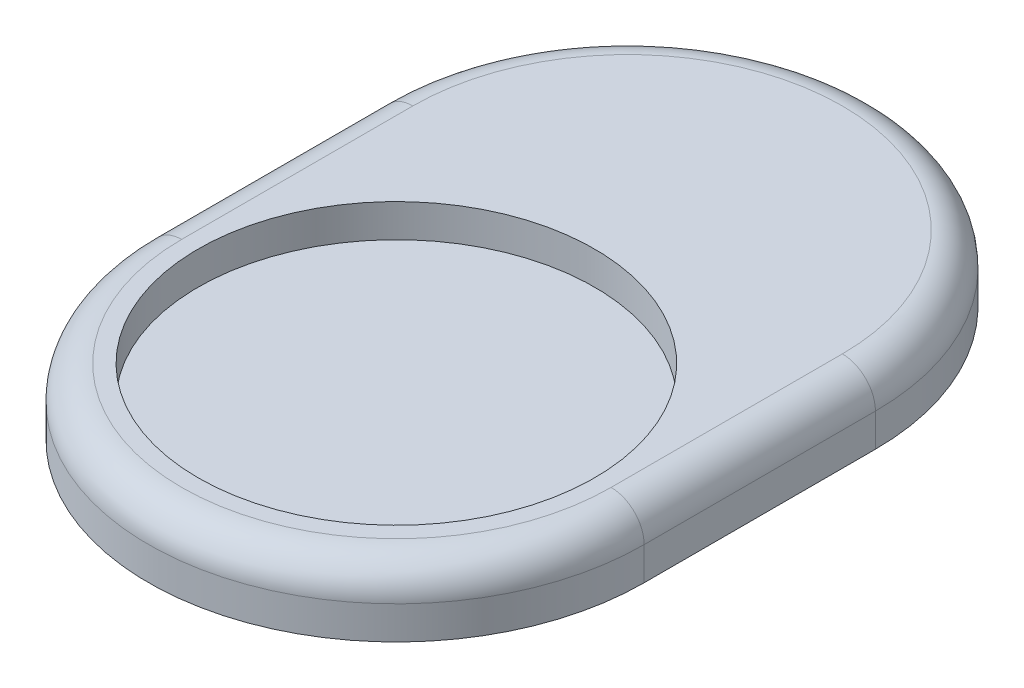
from build123d import *

# Parameters (mm, degrees)
BOSS_EXTRUDE2_DEPTH = 2
SKETCH3_R           = 6
CUT_EXTRUDE1_DEPTH  = 1
FILLET2_R           = 1


with BuildPart() as part:
    # Sketch2 → Boss-Extrude2 (new body)
    with BuildSketch(Plane(origin=(0, 0, 0), x_dir=(1, 0, 0), z_dir=(0, 1, 0))):
        with BuildLine():
            Line((-7.5, 0), (-7.5, 7))
            ThreePointArc((-7.5, 7), (0, 14.5), (7.5, 7))
            Line((7.5, 7), (7.5, 0))
            ThreePointArc((7.5, 0), (0, -7.5), (-7.5, 0))
        make_face()
    extrude(amount=BOSS_EXTRUDE2_DEPTH)

    # Sketch3 → Cut-Extrude1 (cut)
    with BuildSketch(Plane(origin=(0, 2, 0), x_dir=(1, 0, 0), z_dir=(0, 1, 0))):
        Circle(SKETCH3_R)
    extrude(amount=-CUT_EXTRUDE1_DEPTH, mode=Mode.SUBTRACT)

    # Fillet2
    fillet2_edges = [part.edges().sort_by_distance(p)[0] for p in [
        (0, 2, -14.5),
        (-7.5, 2, -3.5),
        (0, 2, 7.5),
        (7.5, 2, -3.5),
    ]]
    fillet(fillet2_edges, radius=FILLET2_R)


solid = part.part
